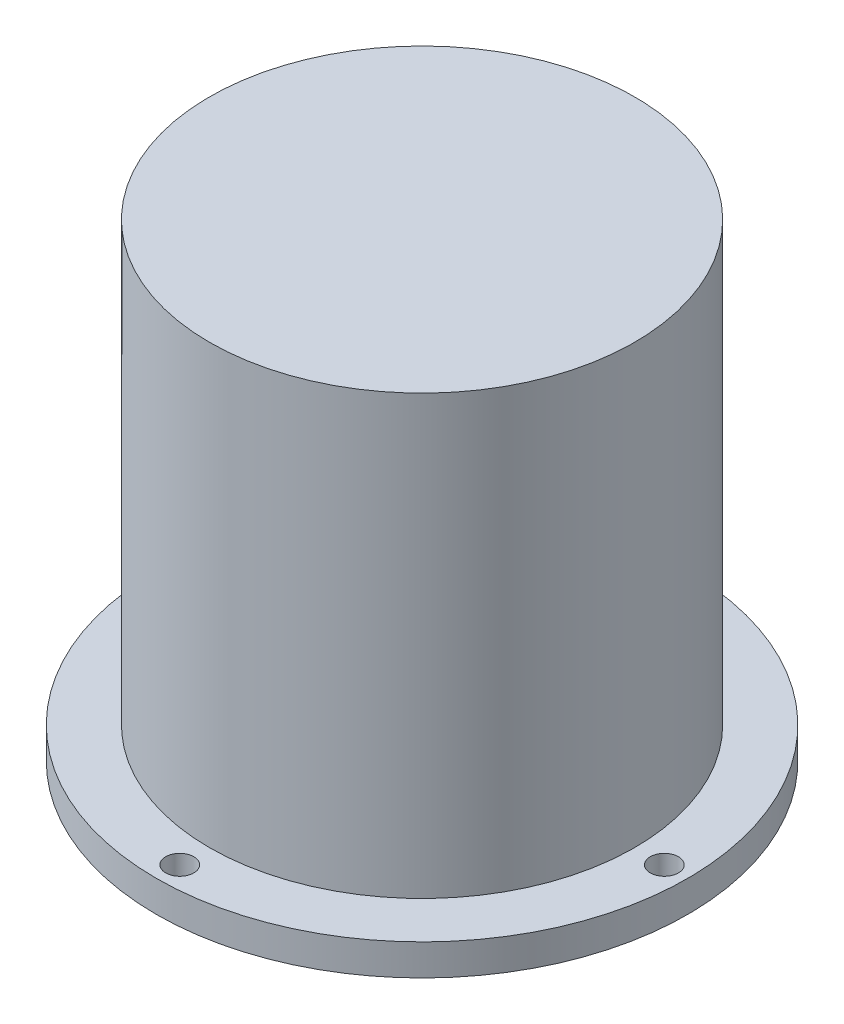
from build123d import *

# Parameters (mm, degrees)
ESQUISSE1_R        = 42.5
BOSS_EXTRU_2_DEPTH = 5
D_GAGEMENT_M42_D   = 4.5
ESQUISSE12_R       = 34
BOSS_EXTRU_3_DEPTH = 70


with BuildPart() as part:
    # Esquisse1 → Boss.-Extru.2 (new body)
    with BuildSketch(Plane(origin=(0, 0, 0), x_dir=(1, 0, 0), z_dir=(0, 1, 0))):
        Circle(ESQUISSE1_R)
    extrude(amount=BOSS_EXTRU_2_DEPTH)

    # Dégagement M42 (through all)
    with Locations(Plane(origin=(0, 5, -38.75), x_dir=(0, 0, 1), z_dir=(0, 1, 0))):
        with Locations((0, 0), (38.75, -38.75), (77.5, 0), (38.75, 38.75)):
            Hole(D_GAGEMENT_M42_D / 2)

    # Esquisse12 → Boss.-Extru.3 (add)
    with BuildSketch(Plane(origin=(0, 5, 0), x_dir=(1, 0, 0), z_dir=(0, 1, 0))):
        Circle(ESQUISSE12_R)
    extrude(amount=BOSS_EXTRU_3_DEPTH)


solid = part.part
